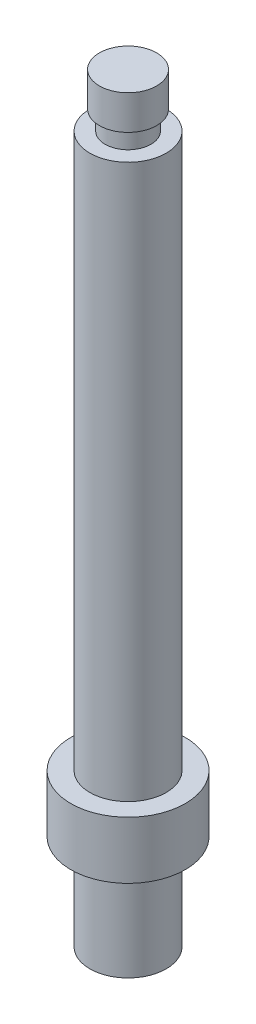
from build123d import *

# Parameters (mm, degrees)
TROU_TARAUD_M31_D           = 2.5
TROU_TARAUD_M31_DEPTH       = 8.5
TROU_TARAUD_M31_CSINK_D     = 3.05
TROU_TARAUD_M31_CSINK_ANGLE = 90
TROU_TARAUD_M31_TIP         = 0.751075774


with BuildPart() as part:
    # Esquisse1 → Révolution1 (revolve)
    with BuildSketch(Plane.XY):
        Polygon((0, 0), (-0.5, 0), (-0.5, -29), (-1.5, -29), (-1.5, -32), (-0.5, -32), (-0.5, -37), (1.5, -37), (1.5, 2.8), (0, 2.8), (0, 1), (0.3, 1), (0.3, 0), align=None)
    revolve(axis=Axis((1.5, -37, 0), (0, 1, 0)))

    # Trou taraudé M31
    with Locations(Plane(origin=(0, -37, 0), x_dir=(-1, 0, 0), z_dir=(0, -1, 0))):
        with Locations((-1.5, 0)):
            CounterSinkHole(TROU_TARAUD_M31_D / 2, TROU_TARAUD_M31_CSINK_D / 2, depth=TROU_TARAUD_M31_DEPTH, counter_sink_angle=TROU_TARAUD_M31_CSINK_ANGLE)
            with Locations((0, 0, -(TROU_TARAUD_M31_DEPTH + TROU_TARAUD_M31_TIP / 2))):  # 118° drill point
                Cone(0, TROU_TARAUD_M31_D / 2, TROU_TARAUD_M31_TIP, mode=Mode.SUBTRACT)


solid = part.part
